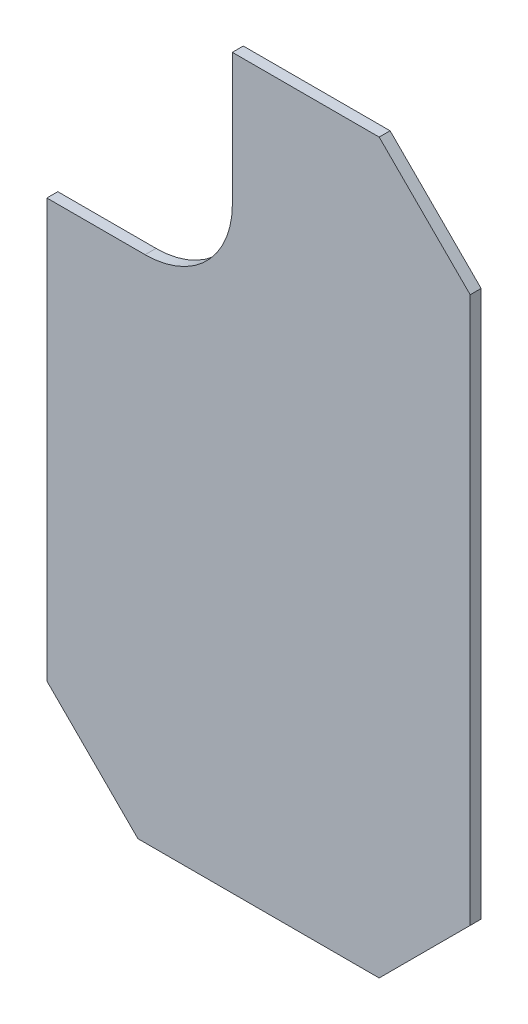
from build123d import *

# Parameters (mm, degrees)
BOSS_EXTRUDE1_DEPTH = 0.762


with BuildPart() as part:
    # Sketch1 → Boss-Extrude1 (new body)
    with BuildSketch(Plane.XY):
        with BuildLine():
            Line((-51.1725, -95.766078244), (-68, -95.766078244))
            Line((-68, -95.766078244), (-74.35, -89.416078244))
            Line((-74.35, -89.416078244), (-74.35, -60.234654728))
            Line((-74.35, -60.234654728), (-67.5, -60.234654728))
            ThreePointArc((-67.5, -60.234654728), (-63.19548747, -58.451667258), (-61.4125, -54.147154728))
            Line((-61.4125, -54.147154728), (-61.4125, -44.966078244))
            Line((-61.4125, -44.966078244), (-51.1725, -44.966078244))
            Line((-51.1725, -44.966078244), (-44.8225, -51.316078244))
            Line((-44.8225, -51.316078244), (-44.8225, -89.416078244))
            Line((-44.8225, -89.416078244), (-51.1725, -95.766078244))
        make_face()
    extrude(amount=BOSS_EXTRUDE1_DEPTH)


solid = part.part
